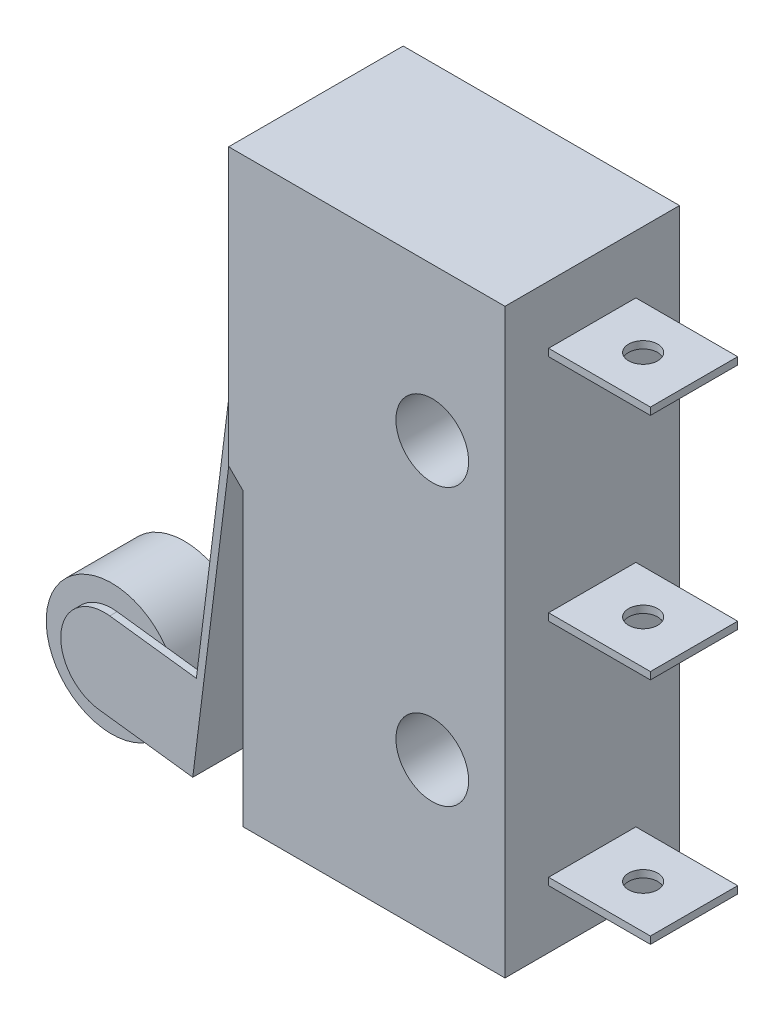
from build123d import *

# Parameters (mm, degrees)
SKETCH_1_R           = 1.25
EXTRUDE_1_DEPTH      = 6
EXTRUDE_2_DEPTH      = 1.5
EXTRUDE_2_DEPTH_BACK = 1.5
EXTRUDE_3_DEPTH      = 0.25
SKETCH_5_R           = 2.25
EXTRUDE_4_DEPTH      = 2.5
SKETCH_6_W           = 3
SKETCH_6_H           = 0.25
EXTRUDE_5_DEPTH      = 3.5
SKETCH_7_R           = 0.5
CUT_EXTRUDE_1_DEPTH  = 20.250480762


with BuildPart() as part:
    # Эскиз1 → Бобышка-Вытянуть1 (new body)
    with BuildSketch(Plane.XY):
        Polygon((0, 0), (0, 10), (-0.5, 10.5), (-0.5, 20), (0, 20), (9, 20), (9, 0), align=None)
        with Locations((6.5, 5.25)):
            Circle(SKETCH_1_R, mode=Mode.SUBTRACT)
        with Locations((6.5, 14.75)):
            Circle(SKETCH_1_R, mode=Mode.SUBTRACT)
    extrude(amount=EXTRUDE_1_DEPTH)

    # Эскиз3 → Бобышка-Вытянуть2 (add, two sides)
    with BuildSketch(Plane(origin=(0, 0, 3), x_dir=(0, -1, 0), z_dir=(0, 0, -1))) as extrude_2_sk:
        with BuildLine():
            Line((-17, 0.5), (-17, 1.029304445))
            ThreePointArc((-17, 1.029304445), (-16.937419544, 1.194755086), (-16.781008684, 1.277373915))
            Line((-16.781008684, 1.277373915), (-13, 1.75))
            Line((-13, 1.75), (0.861001781, 3.482625223))
            Line((0.861001781, 3.482625223), (0.892010464, 3.234555753))
            Line((0.892010464, 3.234555753), (-16.531008684, 1.05667836))
            ThreePointArc((-16.531008684, 1.05667836), (-16.687419544, 0.974059532), (-16.75, 0.808608891))
            Line((-16.75, 0.808608891), (-16.75, 0.5))
            Line((-16.75, 0.5), (-17, 0.5))
        make_face()
    extrude(amount=EXTRUDE_2_DEPTH)
    extrude(extrude_2_sk.sketch, amount=-EXTRUDE_2_DEPTH_BACK)

    # Эскиз4 → Бобышка-Вытянуть3 (add)
    with BuildSketch(Plane.XY.offset(4.5)):
        with BuildLine():
            Line((-3.482625223, -0.861001781), (-6.459458853, -0.488897577))
            ThreePointArc((-6.459458853, -0.488897577), (-7.761823566, 1.18557134), (-6.087354649, 2.487936053))
            Line((-6.087354649, 2.487936053), (-3.110521019, 2.115831849))
            Line((-3.110521019, 2.115831849), (-3.482625223, -0.861001781))
        make_face()
    extrude_3 = extrude(amount=-EXTRUDE_3_DEPTH)

    # Зеркальное отражение1: Бобышка-Вытянуть3 across plane
    add(extrude_3.mirror(Plane(origin=(0, 0, 3), x_dir=(1, 0, 0), z_dir=(0, 0, -1))))

    # Эскиз5 → Бобышка-Вытянуть4 (add)
    with BuildSketch(Plane(origin=(0, 0, 4.25), x_dir=(-1, 0, 0), z_dir=(0, 0, -1))):
        with Locations((6.273406751, 0.999519238)):
            Circle(SKETCH_5_R)
    extrude(amount=EXTRUDE_4_DEPTH)

    # Эскиз6 → Бобышка-Вытянуть5 (add)
    with BuildSketch(Plane(origin=(9, 0, 0), x_dir=(0, 0, -1), z_dir=(1, 0, 0))):
        with Locations((-3, 2.125)):
            Rectangle(SKETCH_6_W, SKETCH_6_H)
        with Locations((-3, 17.875)):
            Rectangle(SKETCH_6_W, SKETCH_6_H)
        with Locations((-3, 10)):
            Rectangle(SKETCH_6_W, SKETCH_6_H)
    extrude(amount=EXTRUDE_5_DEPTH)

    # Эскиз7 → Вырез-Вытянуть1 (cut, through all)
    with BuildSketch(Plane(origin=(0, 18, 0), x_dir=(1, 0, 0), z_dir=(0, 1, 0))):
        with Locations((10.75, -3)):
            Circle(SKETCH_7_R)
    extrude(amount=-CUT_EXTRUDE_1_DEPTH, mode=Mode.SUBTRACT)


solid = part.part
